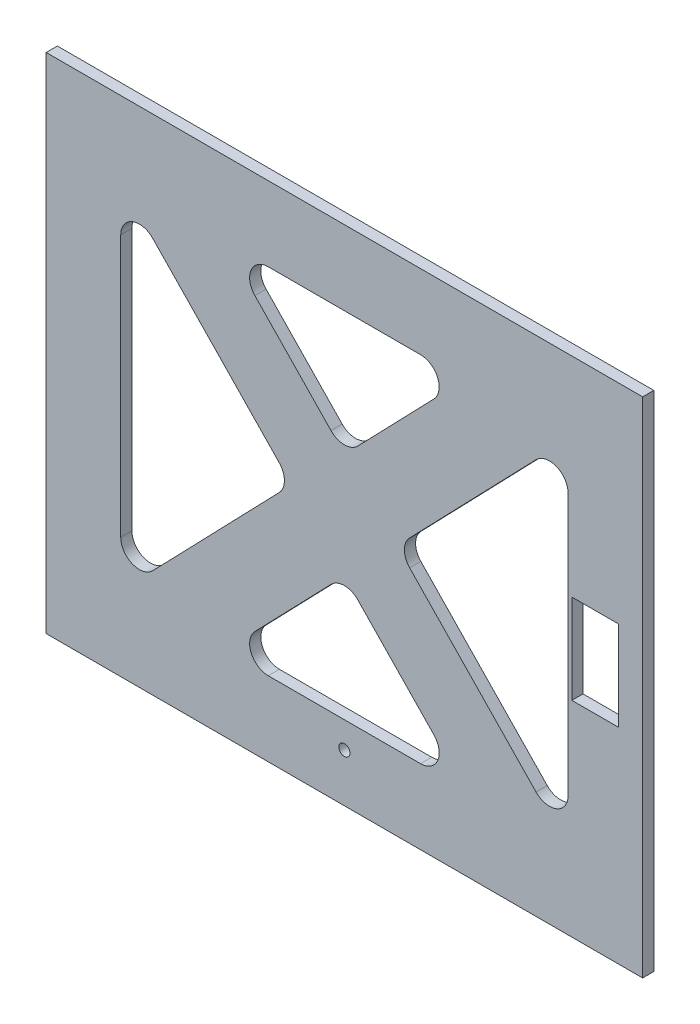
from build123d import *

# Parameters (mm, degrees)
SKETCH1_W           = 160
SKETCH1_H           = 135
BOSS_EXTRUDE1_DEPTH = 3
CUT_EXTRUDE1_DEPTH  = 20
SKETCH3_W           = 10
SKETCH3_H           = 20.2
CUT_EXTRUDE2_DEPTH  = 10
SKETCH5_W           = 10
SKETCH5_H           = 3
BOSS_EXTRUDE2_DEPTH = 30
SKETCH6_W           = 10
SKETCH6_H           = 20.15
CUT_EXTRUDE3_DEPTH  = 30
SKETCH7_W           = 10
SKETCH7_H           = 3
BOSS_EXTRUDE3_DEPTH = 30
SKETCH8_W           = 11.5
SKETCH8_H           = 21.5
CUT_EXTRUDE4_DEPTH  = 10
SKETCH9_W           = 11.5
SKETCH9_H           = 3
BOSS_EXTRUDE5_DEPTH = 30
SKETCH10_W          = 11
SKETCH10_H          = 21
CUT_EXTRUDE5_DEPTH  = 30
SKETCH11_W          = 3
SKETCH11_H          = 21
CUT_EXTRUDE6_DEPTH  = 1.5
SKETCH12_W          = 12.5
SKETCH12_H          = 3
CUT_EXTRUDE7_DEPTH  = 3


with BuildPart() as part:
    # Sketch1 → Boss-Extrude1 (new body)
    with BuildSketch(Plane.XY.offset(152)):
        with Locations((0, 12.91714511)):
            Rectangle(SKETCH1_W, SKETCH1_H)
        with BuildLine():
            Line((-60, -22.204596664), (-60, 48.038886885))
            ThreePointArc((-60, 48.038886885), (-56.872665603, 52.674954566), (-51.402750584, 51.511608676))
            Line((-51.402750584, 51.511608676), (-17.49683417, 16.389866902))
            ThreePointArc((-17.49683417, 16.389866902), (-16.094083586, 12.91714511), (-17.49683417, 9.444423319))
            Line((-17.49683417, 9.444423319), (-51.402750584, -25.677318456))
            ThreePointArc((-51.402750584, -25.677318456), (-56.872665603, -26.840664345), (-60, -22.204596664))
        make_face(mode=Mode.SUBTRACT)
        with BuildLine():
            Line((20.424315219, 60.41714511), (-20.424315219, 60.41714511))
            ThreePointArc((-20.424315219, 60.41714511), (-25.026684661, 57.371165459), (-24.021564635, 51.944423319))
            Line((-24.021564635, 51.944423319), (-3.597249416, 30.787716735))
            ThreePointArc((-3.597249416, 30.787716735), (0, 29.260438526), (3.597249416, 30.787716735))
            Line((3.597249416, 30.787716735), (24.021564635, 51.944423319))
            ThreePointArc((24.021564635, 51.944423319), (25.026684661, 57.371165459), (20.424315219, 60.41714511))
        make_face(mode=Mode.SUBTRACT)
        with BuildLine():
            Line((51.402750584, 51.511608676), (17.49683417, 16.389866902))
            ThreePointArc((17.49683417, 16.389866902), (16.094083586, 12.91714511), (17.49683417, 9.444423319))
            Line((17.49683417, 9.444423319), (51.402750584, -25.677318456))
            ThreePointArc((51.402750584, -25.677318456), (56.872665603, -26.840664345), (60, -22.204596664))
            Line((60, -22.204596664), (60, 48.038886885))
            ThreePointArc((60, 48.038886885), (56.872665603, 52.674954566), (51.402750584, 51.511608676))
        make_face(mode=Mode.SUBTRACT)
        with BuildLine():
            Line((-24.021564635, -26.110133098), (-3.597249416, -4.953426514))
            ThreePointArc((-3.597249416, -4.953426514), (0, -3.426148305), (3.597249416, -4.953426514))
            Line((3.597249416, -4.953426514), (24.021564635, -26.110133098))
            ThreePointArc((24.021564635, -26.110133098), (25.026684661, -31.536875238), (20.424315219, -34.58285489))
            Line((20.424315219, -34.58285489), (-20.424315219, -34.58285489))
            ThreePointArc((-20.424315219, -34.58285489), (-25.026684661, -31.536875238), (-24.021564635, -26.110133098))
        make_face(mode=Mode.SUBTRACT)
    extrude(amount=BOSS_EXTRUDE1_DEPTH)

    # Sketch2 → Cut-Extrude1 (cut)
    with BuildSketch(Plane.XY.offset(155)):
        with BuildLine():
            ThreePointArc((1.5, -41.631936217), (0, -40.131936217), (-1.5, -41.631936217))
            Line((-1.5, -41.631936217), (1.5, -41.631936217))
        make_face()
        with BuildLine():
            Line((1.5, -41.631936217), (-1.5, -41.631936217))
            ThreePointArc((-1.5, -41.631936217), (0, -43.131936217), (1.5, -41.631936217))
        make_face()
    extrude(amount=-CUT_EXTRUDE1_DEPTH, mode=Mode.SUBTRACT)

    # Sketch3 → Cut-Extrude2 (cut)
    with BuildSketch(Plane(origin=(80, -54.58285489, 155), x_dir=(-1, 0, 0), z_dir=(0, 0, -1))):
        with Locations((13, 65)):
            Rectangle(SKETCH3_W, SKETCH3_H)
    extrude(amount=CUT_EXTRUDE2_DEPTH, mode=Mode.SUBTRACT)

    # Sketch5 → Boss-Extrude2 (add)
    with BuildSketch(Plane(origin=(0, 0.31714511, 0), x_dir=(1, 0, 0), z_dir=(0, 1, 0))):
        with Locations((67, -153.5)):
            Rectangle(SKETCH5_W, SKETCH5_H)
    extrude(amount=BOSS_EXTRUDE2_DEPTH)

    # Sketch6 → Cut-Extrude3 (cut)
    with BuildSketch(Plane.XY.offset(155)):
        with Locations((67, 14.39214511)):
            Rectangle(SKETCH6_W, SKETCH6_H)
    extrude(amount=-CUT_EXTRUDE3_DEPTH, mode=Mode.SUBTRACT)

    # Sketch7 → Boss-Extrude3 (add)
    with BuildSketch(Plane(origin=(0, 4.31714511, 0), x_dir=(1, 0, 0), z_dir=(0, 1, 0))):
        with Locations((67, -153.5)):
            Rectangle(SKETCH7_W, SKETCH7_H)
    extrude(amount=BOSS_EXTRUDE3_DEPTH)

    # Sketch8 → Cut-Extrude4 (cut)
    with BuildSketch(Plane.XY.offset(155)):
        with Locations((73.437153805, 5.004502564)):
            Rectangle(SKETCH8_W, SKETCH8_H)
    extrude(amount=-CUT_EXTRUDE4_DEPTH, mode=Mode.SUBTRACT)

    # Sketch9 → Boss-Extrude5 (add)
    with BuildSketch(Plane(origin=(0, -5.745497436, 0), x_dir=(1, 0, 0), z_dir=(0, 1, 0))):
        with Locations((73.437153805, -153.5)):
            Rectangle(SKETCH9_W, SKETCH9_H)
    extrude(amount=BOSS_EXTRUDE5_DEPTH)

    # Sketch10 → Cut-Extrude5 (cut)
    with BuildSketch(Plane.XY.offset(155)):
        with Locations((66.5, 10.91714511)):
            Rectangle(SKETCH10_W, SKETCH10_H)
    extrude(amount=-CUT_EXTRUDE5_DEPTH, mode=Mode.SUBTRACT)

    # Sketch11 → Cut-Extrude6 (cut)
    with BuildSketch(Plane.ZY.offset(-72)):
        with Locations((153.5, 10.91714511)):
            Rectangle(SKETCH11_W, SKETCH11_H)
    extrude(amount=-CUT_EXTRUDE6_DEPTH, mode=Mode.SUBTRACT)

    # Sketch12 → Cut-Extrude7 (cut)
    with BuildSketch(Plane(origin=(0, 21.41714511, 0), x_dir=(-1, 0, 0), z_dir=(0, -1, 0))):
        with Locations((-67.25, -153.5)):
            Rectangle(SKETCH12_W, SKETCH12_H)
    extrude(amount=-CUT_EXTRUDE7_DEPTH, mode=Mode.SUBTRACT)


solid = part.part
